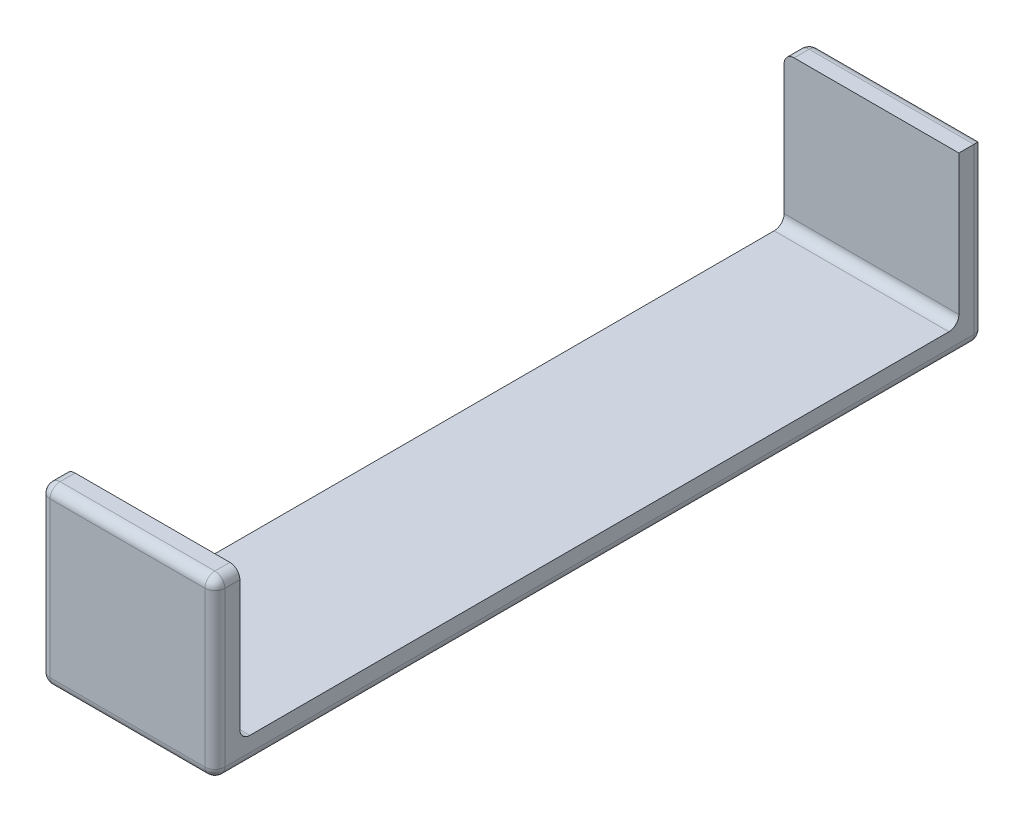
from build123d import *

# Parameters (mm, degrees)
ESQUISSE1_W             = 17.5
ESQUISSE1_H             = 17.5
BOSS_EXTRU_1_DEPTH      = 77
ESQUISSE2_W             = 72
ESQUISSE2_H             = 20
ENL_V_MAT_EXTRU_1_DEPTH = 18.5
CONG_1_R                = 1


with BuildPart() as part:
    # Esquisse1 → Boss.-Extru.1 (new body)
    with BuildSketch(Plane.XY):
        with Locations((8.75, 8.75)):
            Rectangle(ESQUISSE1_W, ESQUISSE1_H)
    extrude(amount=BOSS_EXTRU_1_DEPTH)

    # Esquisse2 → Enlèv. mat.-Extru.1 (cut, through all)
    with BuildSketch(Plane.ZY):
        with Locations((38.5, 12.5)):
            Rectangle(ESQUISSE2_W, ESQUISSE2_H)
    extrude(amount=-ENL_V_MAT_EXTRU_1_DEPTH, mode=Mode.SUBTRACT)

    # Congé1
    cong_1_edges = [part.edges().sort_by_distance(p)[0] for p in [
        (8.75, 17.5, 77),
        (0, 17.5, 1.25),
        (17.5, 8.75, 77),
        (8.75, 2.5, 2.5),
        (8.75, 2.5, 74.5),
        (8.75, 0, 77),
        (17.5, 8.75, 0),
        (8.75, 17.5, 0),
        (0, 8.75, 0),
        (8.75, 0, 0),
        (17.5, 0, 38.5),
        (17.5, 17.5, 75.75),
        (0, 17.5, 75.75),
        (0, 0, 38.5),
        (0, 8.75, 77),
    ]]
    fillet(cong_1_edges, radius=CONG_1_R)


solid = part.part
